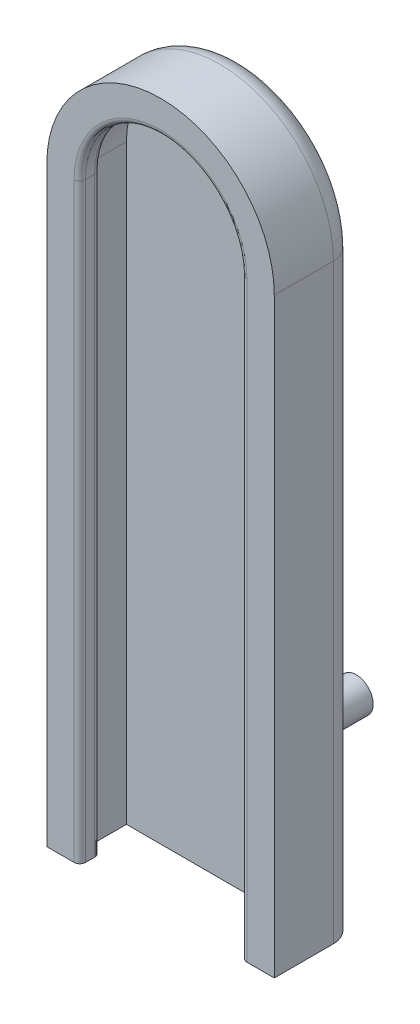
from build123d import *

# Parameters (mm, degrees)
SKETCH1_W            = 10
SKETCH1_H            = 26
BOSS_EXTRUDE1_DEPTH  = 1
BOSS_EXTRUDE5_DEPTH  = 3.6
SKETCH6_W            = 1.45
SKETCH6_H            = 2.6
BOSS_EXTRUDE9_DEPTH  = 26
SKETCH7_W            = 0.55
SKETCH7_H            = 1.7
CUT_EXTRUDE1_DEPTH   = 26
CUT_EXTRUDE3_DEPTH   = 0.9
CUT_EXTRUDE4_DEPTH   = 1.7
FILLET1_R            = 0.25
FILLET2_R            = 1
SKETCH12_R           = 0.75
BOSS_EXTRUDE10_DEPTH = 5


with BuildPart() as part:
    # Sketch1 → Boss-Extrude1 (new body)
    with BuildSketch(Plane.XY):
        with Locations((5, 13)):
            Rectangle(SKETCH1_W, SKETCH1_H)
    extrude(amount=BOSS_EXTRUDE1_DEPTH)

    # Sketch2 → Boss-Extrude5 (add)
    with BuildSketch(Plane(origin=(0, 0, 0), x_dir=(-1, 0, 0), z_dir=(0, 0, -1))):
        with BuildLine():
            Line((-10, 26), (0, 26))
            ThreePointArc((0, 26), (-5, 31), (-10, 26))
        make_face()
    extrude(amount=-BOSS_EXTRUDE5_DEPTH)

    # Sketch6 → Boss-Extrude9 (add)
    with BuildSketch(Plane.XZ):
        with Locations((0.725, 2.3)):
            Rectangle(SKETCH6_W, SKETCH6_H)
        with Locations((9.275, 2.3)):
            Rectangle(SKETCH6_W, SKETCH6_H)
    extrude(amount=-BOSS_EXTRUDE9_DEPTH)

    # Sketch7 → Cut-Extrude1 (cut)
    with BuildSketch(Plane.XZ):
        with Locations((1.175, 1.85)):
            Rectangle(SKETCH7_W, SKETCH7_H)
        with Locations((8.825, 1.85)):
            Rectangle(SKETCH7_W, SKETCH7_H)
    extrude(amount=-CUT_EXTRUDE1_DEPTH, mode=Mode.SUBTRACT)

    # Sketch10 → Cut-Extrude3 (cut)
    with BuildSketch(Plane.XY.offset(3.6)):
        with BuildLine():
            Line((1.45, 26), (8.55, 26))
            ThreePointArc((8.55, 26), (5, 29.55), (1.45, 26))
        make_face()
    extrude(amount=-CUT_EXTRUDE3_DEPTH, mode=Mode.SUBTRACT)

    # Sketch11 → Cut-Extrude4 (cut)
    with BuildSketch(Plane.XY.offset(1)):
        with BuildLine():
            Line((0.9, 26), (9.1, 26))
            ThreePointArc((9.1, 26), (5, 30.1), (0.9, 26))
        make_face()
    extrude(amount=CUT_EXTRUDE4_DEPTH, mode=Mode.SUBTRACT)

    # Fillet1
    fillet1_edges = [part.edges().sort_by_distance(p)[0] for p in [
        (1.45, 13, 3.6),
        (8.55, 13, 3.6),
        (1.45, 13, 2.7),
        (8.55, 13, 2.7),
        (5, 29.55, 2.7),
        (5, 29.55, 3.6),
    ]]
    fillet(fillet1_edges, radius=FILLET1_R)

    # Fillet2
    fillet2_edges = [part.edges().sort_by_distance(p)[0] for p in [
        (5, 31, 0),
        (10, 13, 0),
        (0, 13, 0),
    ]]
    fillet(fillet2_edges, radius=FILLET2_R)

    # Sketch12 → Boss-Extrude10 (add)
    with BuildSketch(Plane(origin=(0, 0, 0), x_dir=(-1, 0, 0), z_dir=(0, 0, -1))):
        with Locations((-5, 4)):
            Circle(SKETCH12_R)
    extrude(amount=BOSS_EXTRUDE10_DEPTH)


solid = part.part
